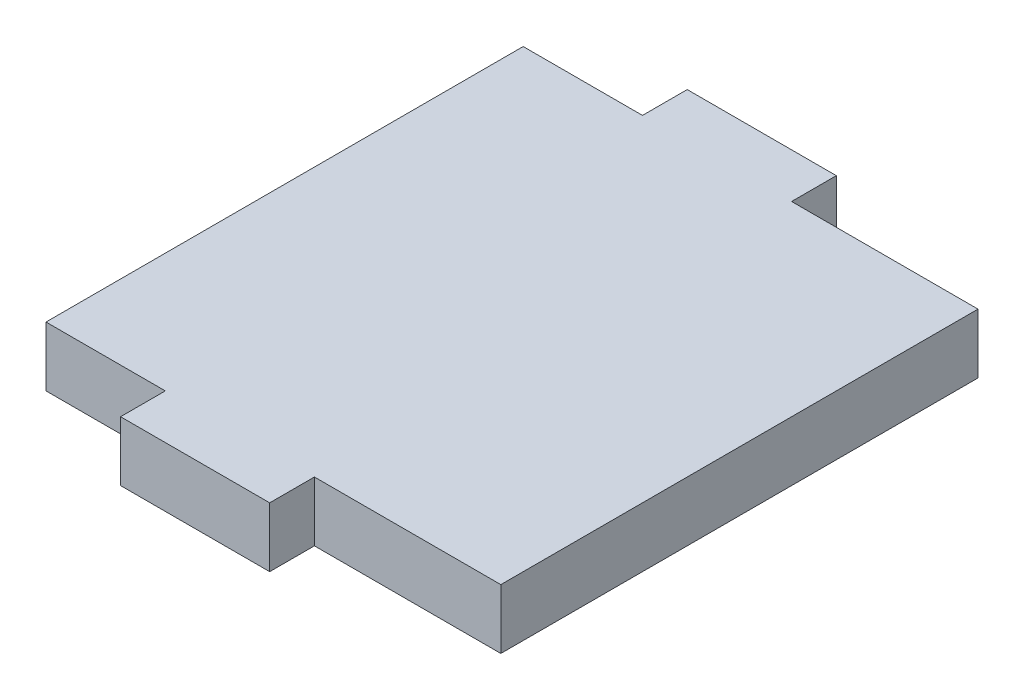
from build123d import *

# Parameters (mm, degrees)
BOSS_EXTRU_1_DEPTH = 4


with BuildPart() as part:
    # Esquisse1 → Boss.-Extru.1 (new body)
    with BuildSketch(Plane(origin=(0, 0, 0), x_dir=(1, 0, 0), z_dir=(0, 1, 0))):
        Polygon((2.75, -19), (-7.25, -19), (-7.25, -16), (-15.25, -16), (-15.25, 16), (-7.25, 16), (-7.25, 19), (2.75, 19), (2.75, 16), (15.25, 16), (15.25, -16), (2.75, -16), align=None)
    extrude(amount=BOSS_EXTRU_1_DEPTH)


solid = part.part
